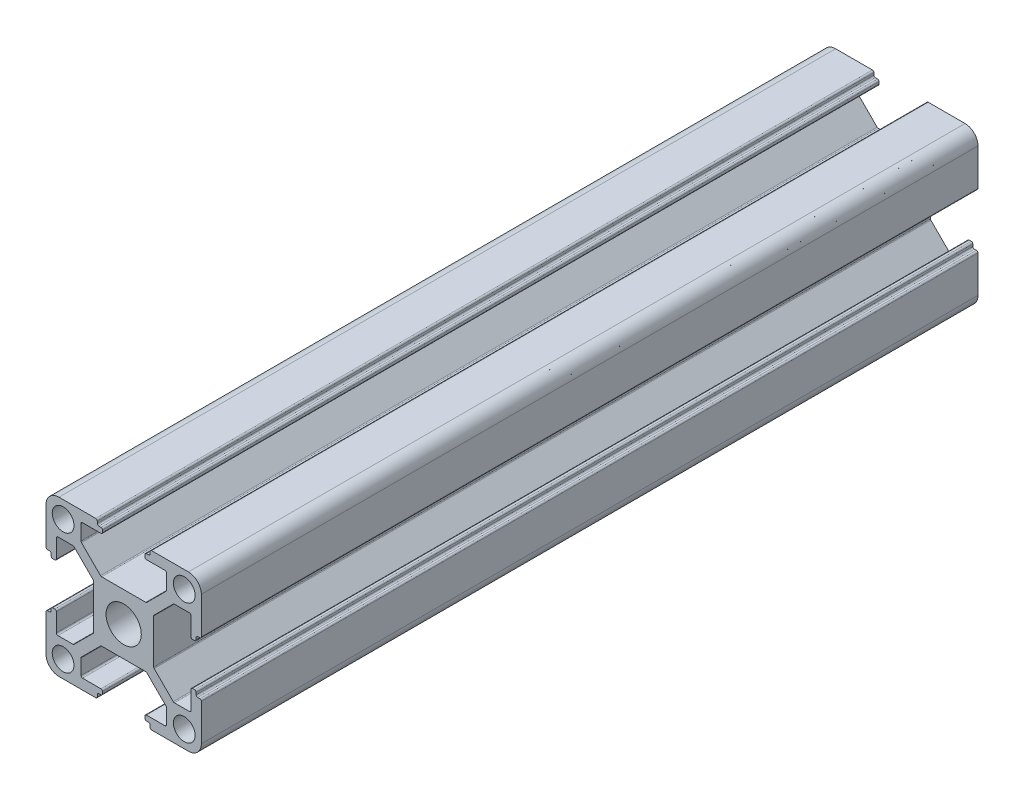
from build123d import *

# Parameters (mm, degrees)
CROQUIS1_R              = 2.1
CROQUIS1_R_2            = 3.4
SALIENTE_EXTRUIR1_DEPTH = 400
CROQUIS2_W              = 39.308064919
CROQUIS2_H              = 32.219725343
CORTAR_EXTRUIR1_DEPTH   = 250


with BuildPart() as part:
    # Croquis1 → Saliente-Extruir1 (new body)
    with BuildSketch(Plane(origin=(0, 0, -50), x_dir=(-1, 0, 0), z_dir=(0, 0, -1))):
        with BuildLine():
            Line((14.7, -5.1), (14.3, -5.1))
            ThreePointArc((14.3, -5.1), (14.087867966, -5.012132034), (14, -4.8))
            Line((14, -4.8), (14, -4.4))
            ThreePointArc((14, -4.4), (13.912132034, -4.187867966), (13.7, -4.1))
            Line((13.7, -4.1), (13.3, -4.1))
            ThreePointArc((13.3, -4.1), (13.087867966, -4.187867966), (13, -4.4))
            Line((13, -4.4), (13, -7.95))
            ThreePointArc((13, -7.95), (12.912132034, -8.162132034), (12.7, -8.25))
            Line((12.7, -8.25), (9.789264108, -8.25))
            ThreePointArc((9.789264108, -8.25), (9.674477865, -8.22717164), (9.577160832, -8.162160788))
            Line((9.577160832, -8.162160788), (5.887896723, -4.473896751))
            ThreePointArc((5.887896723, -4.473896751), (5.822843922, -4.376559778), (5.8, -4.261735963))
            Line((5.8, -4.261735963), (5.8, 4.260735931))
            ThreePointArc((5.8, 4.260735931), (5.82283614, 4.375540961), (5.887867966, 4.472867966))
            Line((5.887867966, 4.472867966), (9.577132034, 8.162132034))
            ThreePointArc((9.577132034, 8.162132034), (9.674459039, 8.22716386), (9.789264069, 8.25))
            Line((9.789264069, 8.25), (12.7, 8.25))
            ThreePointArc((12.7, 8.25), (12.912132034, 8.162132034), (13, 7.95))
            Line((13, 7.95), (13, 4.4))
            ThreePointArc((13, 4.4), (13.087867966, 4.187867966), (13.3, 4.1))
            Line((13.3, 4.1), (13.7, 4.1))
            ThreePointArc((13.7, 4.1), (13.912132034, 4.187867966), (14, 4.4))
            Line((14, 4.4), (14, 4.8))
            ThreePointArc((14, 4.8), (14.087867966, 5.012132034), (14.3, 5.1))
            Line((14.3, 5.1), (14.7, 5.1))
            ThreePointArc((14.7, 5.1), (14.912132034, 5.187867966), (15, 5.4))
            Line((15, 5.4), (15, 12.5))
            ThreePointArc((15, 12.5), (14.267766953, 14.267766953), (12.5, 15))
            Line((12.5, 15), (5.4, 15))
            ThreePointArc((5.4, 15), (5.187867966, 14.912132034), (5.1, 14.7))
            Line((5.1, 14.7), (5.1, 14.3))
            ThreePointArc((5.1, 14.3), (5.012132034, 14.087867966), (4.8, 14))
            Line((4.8, 14), (4.4, 14))
            ThreePointArc((4.4, 14), (4.187867966, 13.912132034), (4.1, 13.7))
            Line((4.1, 13.7), (4.1, 13.3))
            ThreePointArc((4.1, 13.3), (4.187867966, 13.087867966), (4.4, 13))
            Line((4.4, 13), (7.95, 13))
            ThreePointArc((7.95, 13), (8.162132034, 12.912132034), (8.25, 12.7))
            Line((8.25, 12.7), (8.25, 9.788264069))
            ThreePointArc((8.25, 9.788264069), (8.22716386, 9.673459039), (8.162132034, 9.576132034))
            Line((8.162132034, 9.576132034), (4.473867966, 5.887867966))
            ThreePointArc((4.473867966, 5.887867966), (4.376540961, 5.82283614), (4.261735931, 5.8))
            Line((4.261735931, 5.8), (-4.260735892, 5.8))
            ThreePointArc((-4.260735892, 5.8), (-4.375522135, 5.82282836), (-4.472839168, 5.887839212))
            Line((-4.472839168, 5.887839212), (-8.162103277, 9.576103249))
            ThreePointArc((-8.162103277, 9.576103249), (-8.227156078, 9.673440222), (-8.25, 9.788264037))
            Line((-8.25, 9.788264037), (-8.25, 12.7))
            ThreePointArc((-8.25, 12.7), (-8.162132034, 12.912132034), (-7.95, 13))
            Line((-7.95, 13), (-4.4, 13))
            ThreePointArc((-4.4, 13), (-4.187867966, 13.087867966), (-4.1, 13.3))
            Line((-4.1, 13.3), (-4.1, 13.7))
            ThreePointArc((-4.1, 13.7), (-4.187867966, 13.912132034), (-4.4, 14))
            Line((-4.4, 14), (-4.8, 14))
            ThreePointArc((-4.8, 14), (-5.012132034, 14.087867966), (-5.1, 14.3))
            Line((-5.1, 14.3), (-5.1, 14.7))
            ThreePointArc((-5.1, 14.7), (-5.187867966, 14.912132034), (-5.4, 15))
            Line((-5.4, 15), (-12.5, 15))
            ThreePointArc((-12.5, 15), (-14.267766953, 14.267766953), (-15, 12.5))
            Line((-15, 12.5), (-15, 5.4))
            ThreePointArc((-15, 5.4), (-14.912132034, 5.187867966), (-14.7, 5.1))
            Line((-14.7, 5.1), (-14.3, 5.1))
            ThreePointArc((-14.3, 5.1), (-14.087867966, 5.012132034), (-14, 4.8))
            Line((-14, 4.8), (-14, 4.4))
            ThreePointArc((-14, 4.4), (-13.912132034, 4.187867966), (-13.7, 4.1))
            Line((-13.7, 4.1), (-13.3, 4.1))
            ThreePointArc((-13.3, 4.1), (-13.087867966, 4.187867966), (-13, 4.4))
            Line((-13, 4.4), (-13, 7.95))
            ThreePointArc((-13, 7.95), (-12.912132034, 8.162132034), (-12.7, 8.25))
            Line((-12.7, 8.25), (-9.788264037, 8.25))
            ThreePointArc((-9.788264037, 8.25), (-9.673440222, 8.227156078), (-9.576103249, 8.162103277))
            Line((-9.576103249, 8.162103277), (-5.887839212, 4.472839168))
            ThreePointArc((-5.887839212, 4.472839168), (-5.82282836, 4.375522135), (-5.8, 4.260735892))
            Line((-5.8, 4.260735892), (-5.8, -4.261735931))
            ThreePointArc((-5.8, -4.261735931), (-5.82283614, -4.376540961), (-5.887867966, -4.473867966))
            Line((-5.887867966, -4.473867966), (-9.576132034, -8.162132034))
            ThreePointArc((-9.576132034, -8.162132034), (-9.673459039, -8.22716386), (-9.788264069, -8.25))
            Line((-9.788264069, -8.25), (-12.7, -8.25))
            ThreePointArc((-12.7, -8.25), (-12.912132034, -8.162132034), (-13, -7.95))
            Line((-13, -7.95), (-13, -4.4))
            ThreePointArc((-13, -4.4), (-13.087867966, -4.187867966), (-13.3, -4.1))
            Line((-13.3, -4.1), (-13.7, -4.1))
            ThreePointArc((-13.7, -4.1), (-13.912132034, -4.187867966), (-14, -4.4))
            Line((-14, -4.4), (-14, -4.8))
            ThreePointArc((-14, -4.8), (-14.087867966, -5.012132034), (-14.3, -5.1))
            Line((-14.3, -5.1), (-14.7, -5.1))
            ThreePointArc((-14.7, -5.1), (-14.912132034, -5.187867966), (-15, -5.4))
            Line((-15, -5.4), (-15, -12.5))
            ThreePointArc((-15, -12.5), (-14.267766953, -14.267766953), (-12.5, -15))
            Line((-12.5, -15), (-5.4, -15))
            ThreePointArc((-5.4, -15), (-5.187867966, -14.912132034), (-5.1, -14.7))
            Line((-5.1, -14.7), (-5.1, -14.3))
            ThreePointArc((-5.1, -14.3), (-5.012132034, -14.087867966), (-4.8, -14))
            Line((-4.8, -14), (-4.4, -14))
            ThreePointArc((-4.4, -14), (-4.187867966, -13.912132034), (-4.1, -13.7))
            Line((-4.1, -13.7), (-4.1, -13.3))
            ThreePointArc((-4.1, -13.3), (-4.187867966, -13.087867966), (-4.4, -13))
            Line((-4.4, -13), (-7.95, -13))
            ThreePointArc((-7.95, -13), (-8.162132034, -12.912132034), (-8.25, -12.7))
            Line((-8.25, -12.7), (-8.25, -9.789264069))
            ThreePointArc((-8.25, -9.789264069), (-8.22716386, -9.674459039), (-8.162132034, -9.577132034))
            Line((-8.162132034, -9.577132034), (-4.472867966, -5.887867966))
            ThreePointArc((-4.472867966, -5.887867966), (-4.375540961, -5.82283614), (-4.260735931, -5.8))
            Line((-4.260735931, -5.8), (4.261735963, -5.8))
            ThreePointArc((4.261735963, -5.8), (4.376559778, -5.822843922), (4.473896751, -5.887896723))
            Line((4.473896751, -5.887896723), (8.162160788, -9.577160832))
            ThreePointArc((8.162160788, -9.577160832), (8.22717164, -9.674477865), (8.25, -9.789264108))
            Line((8.25, -9.789264108), (8.25, -12.7))
            ThreePointArc((8.25, -12.7), (8.162132034, -12.912132034), (7.95, -13))
            Line((7.95, -13), (4.4, -13))
            ThreePointArc((4.4, -13), (4.187867966, -13.087867966), (4.1, -13.3))
            Line((4.1, -13.3), (4.1, -13.7))
            ThreePointArc((4.1, -13.7), (4.187867966, -13.912132034), (4.4, -14))
            Line((4.4, -14), (4.8, -14))
            ThreePointArc((4.8, -14), (5.012132034, -14.087867966), (5.1, -14.3))
            Line((5.1, -14.3), (5.1, -14.7))
            ThreePointArc((5.1, -14.7), (5.187867966, -14.912132034), (5.4, -15))
            Line((5.4, -15), (12.5, -15))
            ThreePointArc((12.5, -15), (14.267766953, -14.267766953), (15, -12.5))
            Line((15, -12.5), (15, -5.4))
            ThreePointArc((15, -5.4), (14.912132034, -5.187867966), (14.7, -5.1))
        make_face()
        with Locations((-11.7, 11.7)):
            Circle(CROQUIS1_R, mode=Mode.SUBTRACT)
        with Locations((-11.7, -11.7)):
            Circle(CROQUIS1_R, mode=Mode.SUBTRACT)
        Circle(CROQUIS1_R_2, mode=Mode.SUBTRACT)
        with Locations((11.7, 11.7)):
            Circle(CROQUIS1_R, mode=Mode.SUBTRACT)
        with Locations((11.7, -11.7)):
            Circle(CROQUIS1_R, mode=Mode.SUBTRACT)
    extrude(amount=-SALIENTE_EXTRUIR1_DEPTH)

    # Croquis2 → Cortar-Extruir1 (cut)
    with BuildSketch(Plane(origin=(0, 0, -50), x_dir=(-1, 0, 0), z_dir=(0, 0, -1))):
        with Locations((0.664531836, 0.281922596)):
            Rectangle(CROQUIS2_W, CROQUIS2_H)
    extrude(amount=-CORTAR_EXTRUIR1_DEPTH, mode=Mode.SUBTRACT)


solid = part.part
